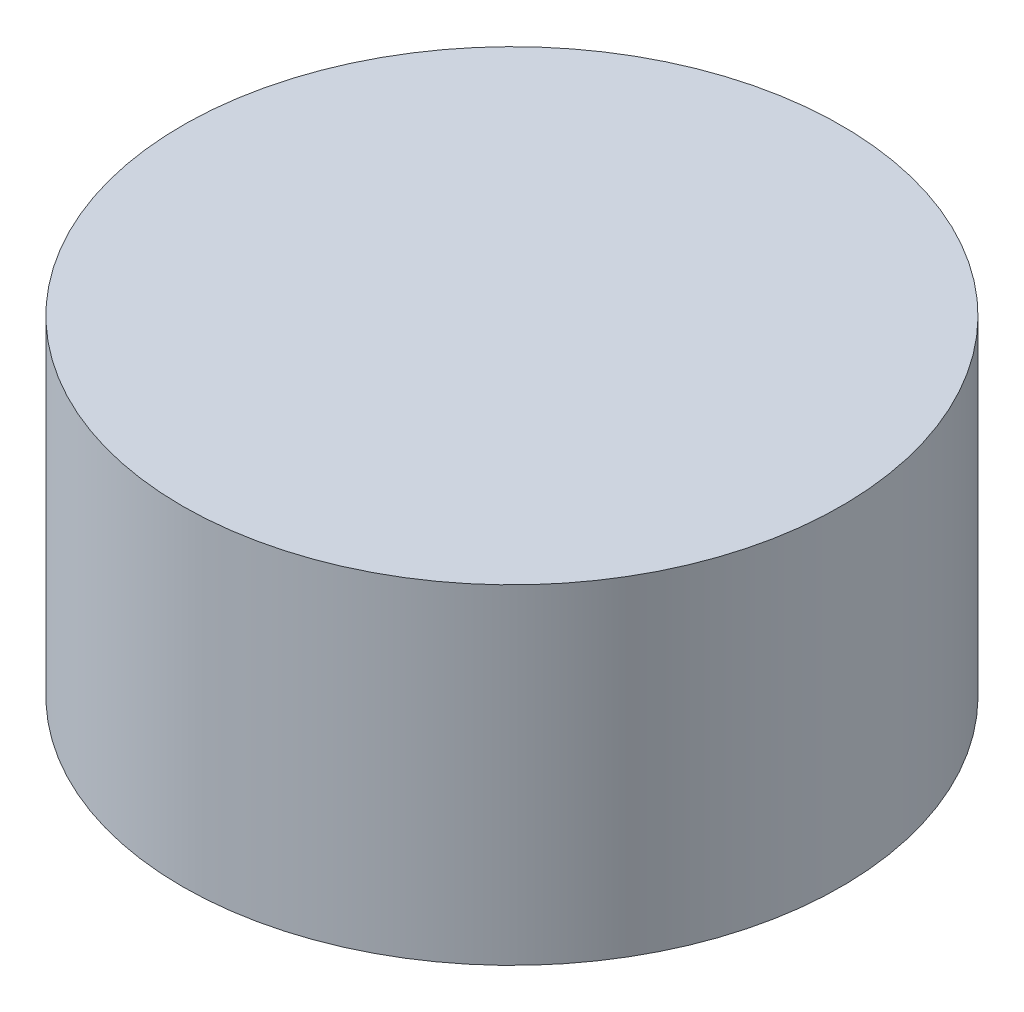
from build123d import *

# Parameters (mm, degrees)
SKETCH1_R           = 0.79375
BOSS_EXTRUDE1_DEPTH = 0.79375


with BuildPart() as part:
    # Sketch1 → Boss-Extrude1 (new body)
    with BuildSketch(Plane(origin=(0, 0, 0), x_dir=(1, 0, 0), z_dir=(0, 1, 0))):
        Circle(SKETCH1_R)
    extrude(amount=BOSS_EXTRUDE1_DEPTH)


solid = part.part
